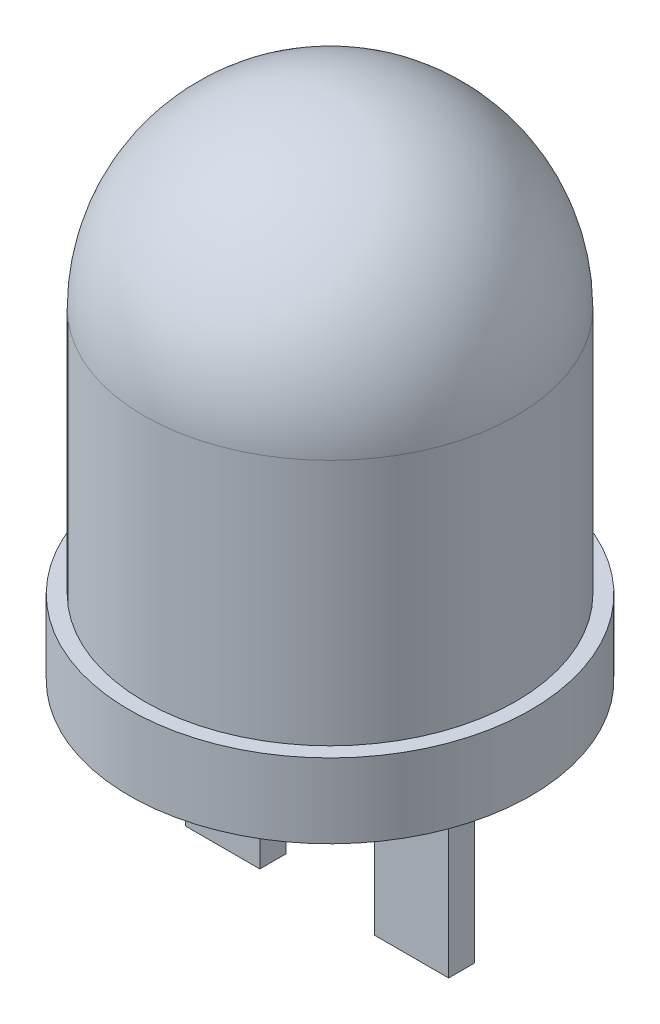
from build123d import *

# Parameters (mm, degrees)
SKETCH2_W                = 2
SKETCH2_H                = 0.7
BOSS_EXTRUDE1_DEPTH      = 5
BOSS_EXTRUDE1_DEPTH_BACK = 5


with BuildPart() as part:
    # Sketch1 → Revolve1 (revolve)
    with BuildSketch(Plane.XY):
        with BuildLine():
            Line((0, 0), (0, 13.65))
            ThreePointArc((0, 13.65), (3.535533906, 12.185533906), (5, 8.65))
            Line((5, 8.65), (5, 2))
            Line((5, 2), (5.4, 2))
            Line((5.4, 2), (5.4, 0))
            Line((5.4, 0), (0, 0))
        make_face()
    revolve(axis=Axis((0, 0, 0), (0, 1, 0)))

    # Sketch2 → Boss-Extrude1 (add, two sides)
    with BuildSketch(Plane.XZ) as boss_extrude1_sk:
        with Locations((2.54, 0)):
            Rectangle(SKETCH2_W, SKETCH2_H)
        with Locations((-2.54, 0)):
            Rectangle(SKETCH2_W, SKETCH2_H)
    extrude(amount=BOSS_EXTRUDE1_DEPTH)
    extrude(boss_extrude1_sk.sketch, amount=-BOSS_EXTRUDE1_DEPTH_BACK)


solid = part.part
